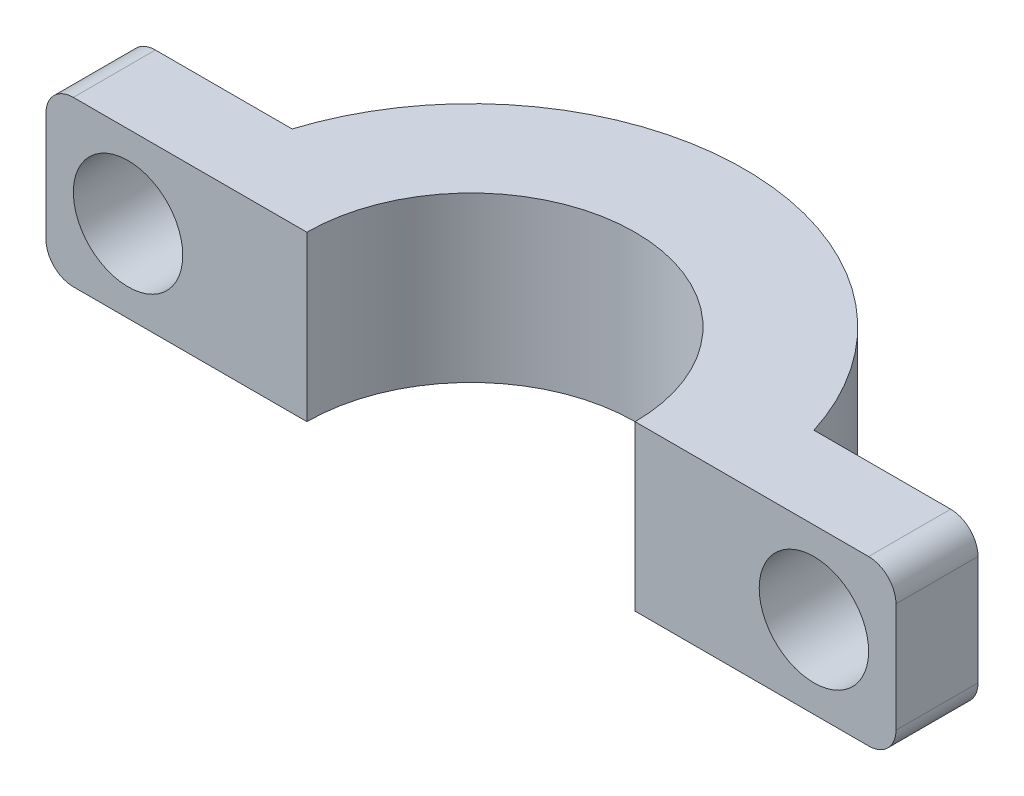
from build123d import *

# Parameters (mm, degrees)
BOSS_EXTRUDE1_DEPTH = 6
BOSS_EXTRUDE2_DEPTH = 6
SKETCH4_R           = 2
CUT_EXTRUDE2_DEPTH  = 11
FILLET1_R           = 1


with BuildPart() as part:
    # Sketch1 → Boss-Extrude1 (new body)
    with BuildSketch(Plane(origin=(0, 0, 0), x_dir=(1, 0, 0), z_dir=(0, 1, 0))):
        with BuildLine():
            Line((-10, 0), (-6, 0))
            ThreePointArc((-6, 0), (0, 6), (6, 0))
            Line((6, 0), (10, 0))
            ThreePointArc((10, 0), (0, 10), (-10, 0))
        make_face()
    extrude(amount=BOSS_EXTRUDE1_DEPTH)

    # Sketch3 → Boss-Extrude2 (add)
    with BuildSketch(Plane(origin=(0, 6, 0), x_dir=(1, 0, 0), z_dir=(0, 1, 0))):
        with BuildLine():
            Line((-10, 0), (-15.539392014, 0))
            Line((-15.539392014, 0), (-15.539392014, 3))
            Line((-15.539392014, 3), (-9.539392014, 3))
            ThreePointArc((-9.539392014, 3), (-9.884177258, 1.517576993), (-10, 0))
        make_face()
    boss_extrude2 = extrude(amount=-BOSS_EXTRUDE2_DEPTH)

    # Sketch4 → Cut-Extrude2 (cut, through all)
    with BuildSketch(Plane.XY):
        with Locations((-12.539392014, 3)):
            Circle(SKETCH4_R)
    cut_extrude2 = extrude(amount=-CUT_EXTRUDE2_DEPTH, mode=Mode.SUBTRACT)

    # Mirror2: Boss-Extrude2, Cut-Extrude2 across plane
    add(boss_extrude2.mirror(Plane(origin=(0, 0, 0), x_dir=(0, 0, 1), z_dir=(1, 0, 0))))
    add(cut_extrude2.mirror(Plane(origin=(0, 0, 0), x_dir=(0, 0, 1), z_dir=(1, 0, 0))), mode=Mode.SUBTRACT)

    # Fillet1
    fillet1_edges = [part.edges().sort_by_distance(p)[0] for p in [
        (-15.539392014, 6, -1.5),
        (-15.539392014, 0, -1.5),
        (15.539392014, 6, -1.5),
        (15.539392014, 0, -1.5),
    ]]
    fillet(fillet1_edges, radius=FILLET1_R)


solid = part.part
